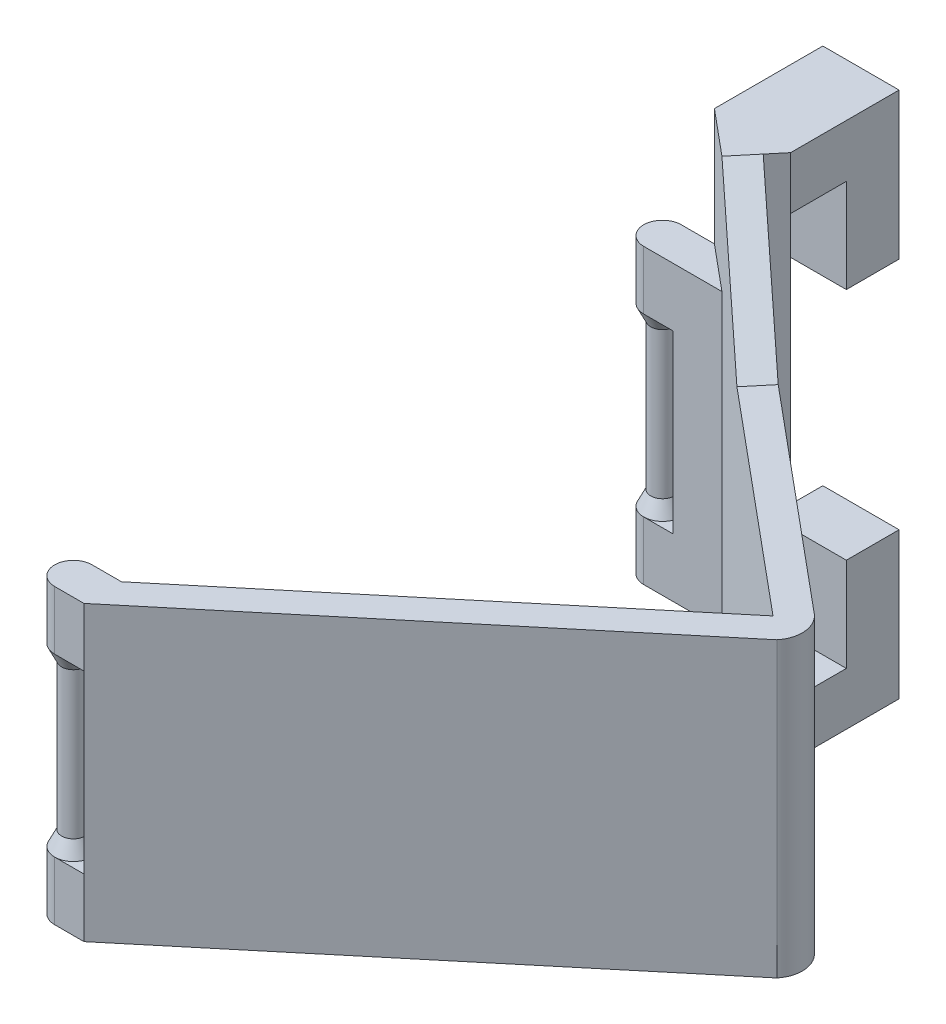
from build123d import *

# Parameters (mm, degrees)
EXTRUDE_1_DEPTH  = 50
EXTRUDE_START    = -50
EXTRUDE_3_DEPTH  = 70
SKETCH_5_W       = 13.017082793
SKETCH_5_H       = 9
EXTRUDE_4_DEPTH  = 18.5
SKETCH_6_W       = 13.017082793
SKETCH_6_H       = 9
EXTRUDE_5_DEPTH  = 16
EXTRUDE_6_DEPTH  = 50
SKETCH_9_W       = 5
SKETCH_9_H       = 6.401843996
EXTRUDE_7_DEPTH  = 10
SKETCH_10_W      = 5
SKETCH_10_H      = 6.401843997
EXTRUDE_8_DEPTH  = 10
SKETCH_11_R      = 2
EXTRUDE_9_DEPTH  = 30
SKETCH_15_R      = 2
EXTRUDE_10_DEPTH = 30
EXTRUDE_11_DEPTH = 5


with BuildPart() as part:
    # 草图1 → 凸台-拉伸1 (new body)
    with BuildSketch(Plane(origin=(0, 0, 0), x_dir=(1, 0, 0), z_dir=(0, 1, 0))):
        with BuildLine():
            Line((7.810249676, 50), (0, 50))
            Line((0, 50), (60, 0))
            Line((60, 0), (-0.663965605, -50.553304671))
            Line((-0.663965605, -50.553304671), (-0.663965605, -56.955148667))
            Line((-0.663965605, -56.955148667), (63.841106398, -3.200921998))
            ThreePointArc((63.841106398, -3.200921998), (64.979466032, 0.45267873), (63.200921998, 3.841106398))
            Line((63.200921998, 3.841106398), (7.810249676, 50))
        make_face()
    extrude(amount=EXTRUDE_1_DEPTH)

    # 草图4 → 凸台-拉伸3 (add)
    with BuildSketch(Plane(origin=(0, 50, 0), x_dir=(1, 0, 0), z_dir=(0, 1, 0)).offset(EXTRUDE_START)):
        Polygon((7.810249676, 50), (0, 50), (7.682212796, 43.598156003), (10.883134794, 47.439262401), align=None)
        Polygon((13.017082793, 50), (7.810249676, 50), (10.883134794, 47.439262401), align=None)
    extrude_3 = extrude(amount=EXTRUDE_3_DEPTH)

    # 草图5 → 凸台-拉伸4 (add)
    with BuildSketch(Plane(origin=(0, 0, -50), x_dir=(-1, 0, 0), z_dir=(0, 0, -1))):
        with Locations((-6.508541397, 65.5)):
            Rectangle(SKETCH_5_W, SKETCH_5_H)
    extrude_4 = extrude(amount=EXTRUDE_4_DEPTH)

    # 草图6 → 凸台-拉伸5 (add)
    with BuildSketch(Plane.XZ.offset(-61)):
        with Locations((6.508541397, -64)):
            Rectangle(SKETCH_6_W, SKETCH_6_H)
    extrude_5 = extrude(amount=EXTRUDE_5_DEPTH)

    # 镜向4: 凸台-拉伸3, 凸台-拉伸4, 凸台-拉伸5 across plane
    add(extrude_3.mirror(Plane(origin=(0, 25, 0), x_dir=(0, 0, 1), z_dir=(0, -1, 0))))
    add(extrude_4.mirror(Plane(origin=(0, 25, 0), x_dir=(0, 0, 1), z_dir=(0, -1, 0))))
    add(extrude_5.mirror(Plane(origin=(0, 25, 0), x_dir=(0, 0, 1), z_dir=(0, -1, 0))))

    # 草图8 → 凸台-拉伸6 (add)
    with BuildSketch(Plane(origin=(0, 50, 0), x_dir=(1, 0, 0), z_dir=(0, 1, 0))):
        Polygon((7.682212796, 43.598156003), (-0.663965605, 43.598156003), (-0.663965605, 50), (0, 50), align=None)
    extrude(amount=-EXTRUDE_6_DEPTH)

    # 草图9 → 凸台-拉伸7 (add)
    with BuildSketch(Plane.XZ):
        with Locations((-3.163965605, 53.754226669)):
            Rectangle(SKETCH_9_W, SKETCH_9_H)
        with BuildLine():
            Line((-5.663965605, 56.955148667), (-5.663965605, 50.553304671))
            ThreePointArc((-5.663965605, 50.553304671), (-8.864887603, 53.754226669), (-5.663965605, 56.955148667))
        make_face()
    extrude_7 = extrude(amount=-EXTRUDE_7_DEPTH)

    # 草图10 → 凸台-拉伸8 (add)
    with BuildSketch(Plane.XZ):
        with Locations((-3.163965605, -46.799078001)):
            Rectangle(SKETCH_10_W, SKETCH_10_H)
        with BuildLine():
            Line((-5.663965605, -43.598156003), (-5.663965605, -50))
            ThreePointArc((-5.663965605, -50), (-8.864887603, -46.799078002), (-5.663965605, -43.598156003))
        make_face()
    extrude_8 = extrude(amount=-EXTRUDE_8_DEPTH)

    # 镜向5: 凸台-拉伸7, 凸台-拉伸8 across plane
    add(extrude_7.mirror(Plane(origin=(0, 25, 0), x_dir=(0, 0, 1), z_dir=(0, -1, 0))))
    add(extrude_8.mirror(Plane(origin=(0, 25, 0), x_dir=(0, 0, 1), z_dir=(0, -1, 0))))

    # 草图11 → 凸台-拉伸9 (add)
    with BuildSketch(Plane.XZ.offset(-40)):
        with Locations((-5.663965605, 53.754226669)):
            Circle(SKETCH_11_R)
    extrude(amount=EXTRUDE_9_DEPTH)

    # 草图14 → 旋转1 (revolve)
    with BuildSketch(Plane(origin=(0, 0, 53.754226669), x_dir=(-1, 0, 0), z_dir=(0, 0, -1))):
        Polygon((7.663965605, 12.5), (7.663965605, 10), (8.864887603, 10), align=None)
        Polygon((7.663965605, 12.5), (8.864887603, 10), (7.663965605, 10), align=None)
    revolve_1 = revolve(axis=Axis((-5.663965605, 10, 53.754226669), (0, 1, 0)))

    # 镜向6: 旋转1 across plane
    add(revolve_1.mirror(Plane(origin=(0, 25, 0), x_dir=(0, 0, 1), z_dir=(0, -1, 0))))

    # 草图15 → 凸台-拉伸10 (add)
    with BuildSketch(Plane(origin=(0, 10, 0), x_dir=(1, 0, 0), z_dir=(0, 1, 0))):
        with Locations((-5.663965605, 46.799078002)):
            Circle(SKETCH_15_R)
    extrude(amount=EXTRUDE_10_DEPTH)

    # 草图17 → 旋转2 (revolve)
    with BuildSketch(Plane.XY.offset(-46.799078002)):
        Polygon((-7.663965605, 10), (-7.663965605, 12.5), (-8.864887603, 10), align=None)
    revolve_2 = revolve(axis=Axis((-5.663965605, 40, -46.799078002), (0, -1, 0)))

    # 镜向7: 旋转2 across plane
    add(revolve_2.mirror(Plane(origin=(0, 25, 0), x_dir=(0, 0, 1), z_dir=(0, -1, 0))))

    # 草图18 → 凸台-拉伸11 (add)
    with BuildSketch(Plane(origin=(24.590163934, 0, -29.508196721), x_dir=(0.76822128, 0, 0.6401844), z_dir=(-0.6401844, 0, 0.76822128))):
        Polygon((-22.009219983, 50), (-22.009219983, 70), (-2.009219983, 50), align=None)
    extrude_11 = extrude(amount=-EXTRUDE_11_DEPTH)

    # 镜向8: 凸台-拉伸11 across plane
    add(extrude_11.mirror(Plane(origin=(0, 25, 0), x_dir=(0, 0, 1), z_dir=(0, -1, 0))))


solid = part.part
